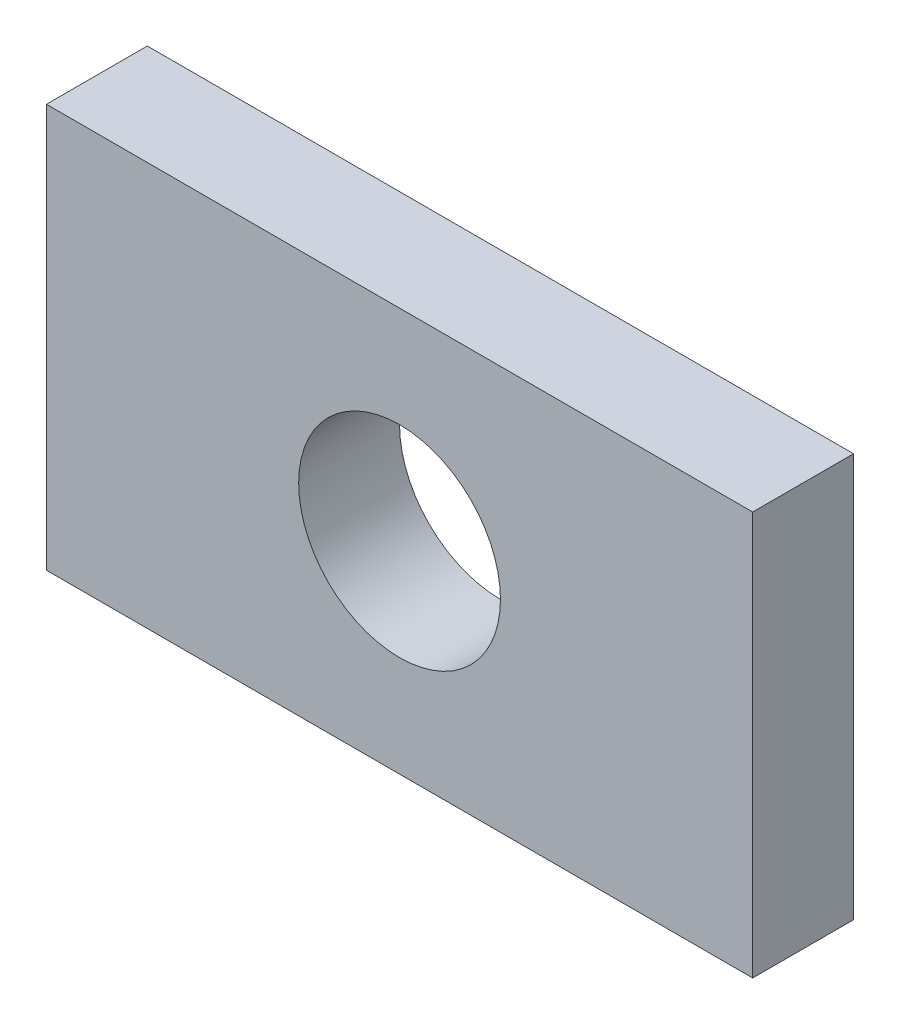
from build123d import *

# Parameters (mm, degrees)
SKETCH1_W           = 17.78
SKETCH1_H           = 10.16
SKETCH1_R           = 2.54
BOSS_EXTRUDE1_DEPTH = 2.54


with BuildPart() as part:
    # Sketch1 → Boss-Extrude1 (new body)
    with BuildSketch(Plane.XY):
        with Locations((8.89, 5.08)):
            Rectangle(SKETCH1_W, SKETCH1_H)
        with Locations((8.89, 5.08)):
            Circle(SKETCH1_R, mode=Mode.SUBTRACT)
    extrude(amount=BOSS_EXTRUDE1_DEPTH)


solid = part.part
